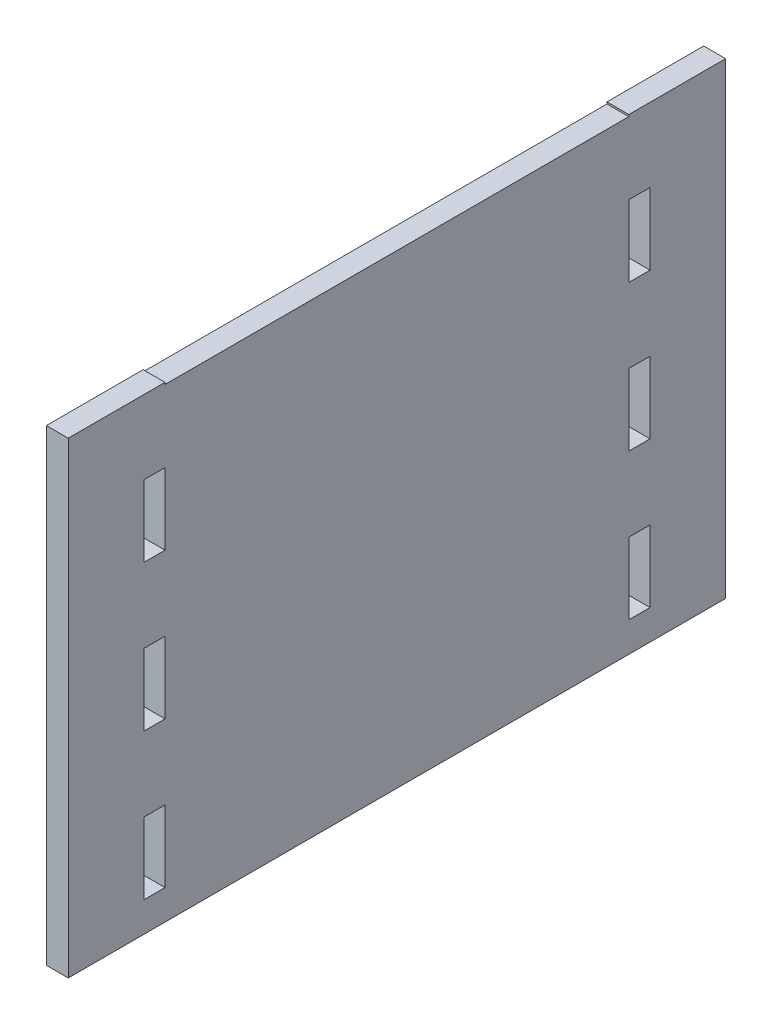
from build123d import *

# Parameters (mm, degrees)
SKETCH1_W           = 90
SKETCH1_H           = 64
BOSS_EXTRUDE1_DEPTH = 3
SKETCH2_W           = 2.9
SKETCH2_H           = 9.8
CUT_EXTRUDE1_DEPTH  = 3
SKETCH4_W           = 63.5
SKETCH4_H           = 0.25
CUT_EXTRUDE2_DEPTH  = 10


with BuildPart() as part:
    # Sketch1 → Boss-Extrude1 (new body)
    with BuildSketch(Plane(origin=(0, 0, 0), x_dir=(0, 0, -1), z_dir=(1, 0, 0))):
        Rectangle(SKETCH1_W, SKETCH1_H)
    extrude(amount=BOSS_EXTRUDE1_DEPTH)

    # Sketch2 → Cut-Extrude1 (cut)
    with BuildSketch(Plane(origin=(3, 0, 0), x_dir=(0, 0, -1), z_dir=(1, 0, 0))):
        with Locations((-33.2, 17)):
            Rectangle(SKETCH2_W, SKETCH2_H)
        with Locations((-33.2, -3)):
            Rectangle(SKETCH2_W, SKETCH2_H)
        with Locations((-33.2, -23)):
            Rectangle(SKETCH2_W, SKETCH2_H)
        with Locations((33.2, -23)):
            Rectangle(SKETCH2_W, SKETCH2_H)
        with Locations((33.2, -3)):
            Rectangle(SKETCH2_W, SKETCH2_H)
        with Locations((33.2, 17)):
            Rectangle(SKETCH2_W, SKETCH2_H)
    extrude(amount=-CUT_EXTRUDE1_DEPTH, mode=Mode.SUBTRACT)

    # Sketch4 → Cut-Extrude2 (cut)
    with BuildSketch(Plane(origin=(3, 0, 0), x_dir=(0, 0, -1), z_dir=(1, 0, 0))):
        with Locations((0, 31.875)):
            Rectangle(SKETCH4_W, SKETCH4_H)
    extrude(amount=-CUT_EXTRUDE2_DEPTH, mode=Mode.SUBTRACT)


solid = part.part
